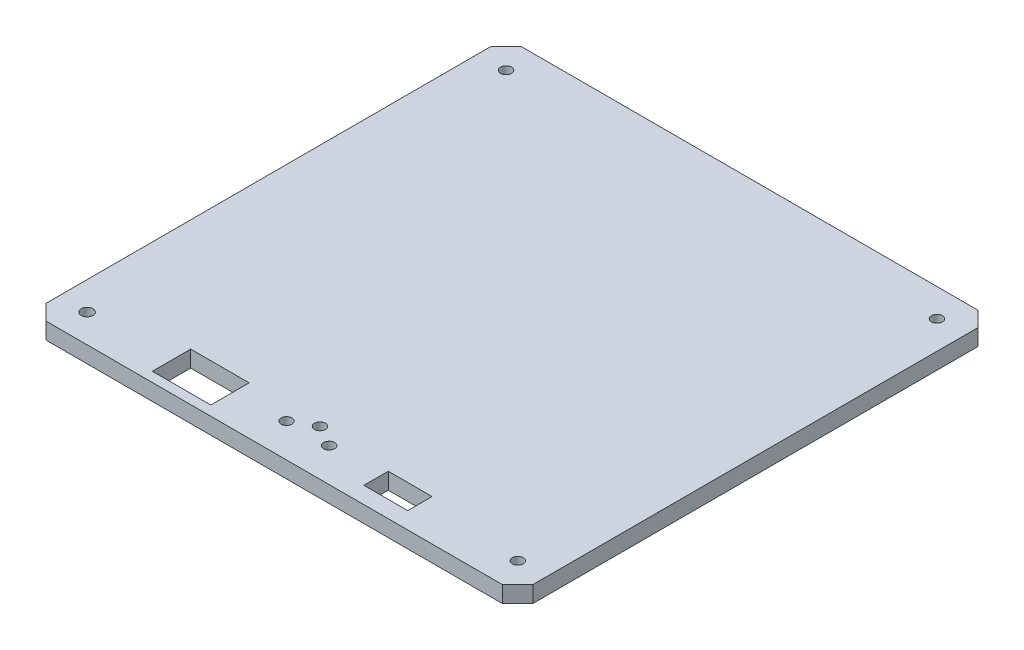
from build123d import *

# Parameters (mm, degrees)
SKETCH1_W           = 150.368
SKETCH1_H           = 150.368
BOSS_EXTRUDE1_DEPTH = 6.858
SKETCH2_W           = 203.2
SKETCH2_H           = 198.374
BOSS_EXTRUDE2_DEPTH = 6.858
SKETCH5_R           = 2.286
CUT_EXTRUDE2_DEPTH  = 6.858
SKETCH6_W           = 18.288
SKETCH6_H           = 10.16
SKETCH6_W_2         = 24.384
SKETCH6_H_2         = 16.002
CUT_EXTRUDE3_DEPTH  = 6.858
SKETCH8_R           = 2.45030007
SKETCH8_R_2         = 2.286
CUT_EXTRUDE8_DEPTH  = 6.858
CUT_EXTRUDE10_DEPTH = 6.858
SKETCH9_W           = 150.368
SKETCH9_H           = 150.368
CUT_EXTRUDE11_DEPTH = 5.08
SKETCH4_R           = 2.286
CUT_EXTRUDE12_DEPTH = 6.858


with BuildPart() as part:
    # Sketch1 → Boss-Extrude1 (new body)
    with BuildSketch(Plane(origin=(0, 0, 0), x_dir=(1, 0, 0), z_dir=(0, 1, 0))):
        Rectangle(SKETCH1_W, SKETCH1_H)
    extrude(amount=BOSS_EXTRUDE1_DEPTH)

    # Sketch2 → Boss-Extrude2 (add)
    with BuildSketch(Plane(origin=(0, 6.858, 0), x_dir=(1, 0, 0), z_dir=(0, 1, 0))):
        Rectangle(SKETCH2_W, SKETCH2_H)
    extrude(amount=-BOSS_EXTRUDE2_DEPTH)

    # Sketch5 → Cut-Extrude2 (cut)
    with BuildSketch(Plane(origin=(0, 6.858, 0), x_dir=(1, 0, 0), z_dir=(0, 1, 0))):
        with Locations((-8.889186327, -85.126681614)):
            Circle(SKETCH5_R)
        with Locations((8.890813673, -85.126681614)):
            Circle(SKETCH5_R)
    extrude(amount=-CUT_EXTRUDE2_DEPTH, mode=Mode.SUBTRACT)

    # Sketch6 → Cut-Extrude3 (cut)
    with BuildSketch(Plane(origin=(0, 0, 0), x_dir=(-1, 0, 0), z_dir=(0, -1, 0))):
        with Locations((-39.624813673, -87.111607671)):
            Rectangle(SKETCH6_W, SKETCH6_H)
        with Locations((42.671186327, -87.111607671)):
            Rectangle(SKETCH6_W_2, SKETCH6_H_2)
    extrude(amount=-CUT_EXTRUDE3_DEPTH, mode=Mode.SUBTRACT)

    # Sketch8 → Cut-Extrude8 (cut)
    with BuildSketch(Plane(origin=(0, 6.858, 0), x_dir=(1, 0, 0), z_dir=(0, 1, 0))):
        with Locations((-89.861846327, -87.359341614)):
            Circle(SKETCH8_R)
        with Locations((89.863473673, -87.359341614)):
            Circle(SKETCH8_R_2)
        with Locations((89.863473673, 87.539978386)):
            Circle(SKETCH8_R_2)
        with Locations((-89.861846327, 87.448846327)):
            Circle(SKETCH8_R_2)
    extrude(amount=-CUT_EXTRUDE8_DEPTH, mode=Mode.SUBTRACT)

    # Sketch7 → Cut-Extrude10 (cut)
    with BuildSketch(Plane(origin=(0, 6.858, 0), x_dir=(1, 0, 0), z_dir=(0, 1, 0))):
        Polygon((101.6, -99.187), (101.6, -92.747495287), (95.341132059, -99.187), align=None)
        Polygon((-95.339504713, 99.187), (-101.6, 99.187), (-101.6, 93.007109855), align=None)
        Polygon((101.6, 92.928132059), (101.6, 99.187), (95.341132059, 99.187), align=None)
        Polygon((-101.6, -92.747495287), (-95.180018996, -99.187), (-101.6, -99.187), align=None)
    extrude(amount=-CUT_EXTRUDE10_DEPTH, mode=Mode.SUBTRACT)

    # Sketch9 → Cut-Extrude11 (cut)
    with BuildSketch(Plane(origin=(0, 0, 0), x_dir=(-1, 0, 0), z_dir=(0, -1, 0))):
        with Locations((0, 3.700326738)):
            Rectangle(SKETCH9_W, SKETCH9_H)
    extrude(amount=-CUT_EXTRUDE11_DEPTH, mode=Mode.SUBTRACT)

    # Sketch4 → Cut-Extrude12 (cut)
    with BuildSketch(Plane(origin=(0, 6.858, 0), x_dir=(1, 0, 0), z_dir=(0, 1, 0))):
        with Locations((0.000813673, -80.046681614)):
            Circle(SKETCH4_R)
    extrude(amount=-CUT_EXTRUDE12_DEPTH, mode=Mode.SUBTRACT)


solid = part.part
